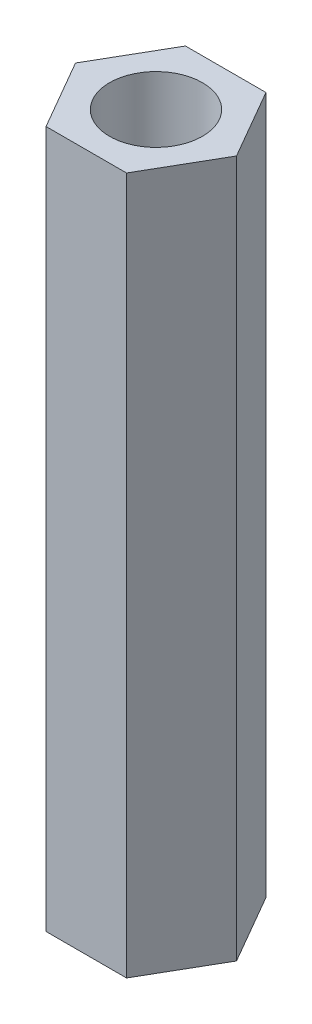
from build123d import *

# Parameters (mm, degrees)
EXTRUDE_1_DEPTH                 = 30
CUT_EXTRUDE_1_REACH             = 32
SKETCH_2_R                      = 2
CUT_EXTRUDE_1_DIRECTION_2_DEPTH = 1


with BuildPart() as part:
    # 草图1 → 凸台-拉伸1 (new body)
    with BuildSketch(Plane(origin=(0, 0, 0), x_dir=(1, 0, 0), z_dir=(0, 1, 0))):
        Polygon((-1.732050808, 3), (1.732050808, 3), (3.464101615, 0), (1.732050808, -3), (-1.732050808, -3), (-3.464101615, 0), align=None)
    extrude(amount=EXTRUDE_1_DEPTH)

    # 草图2 → 切除-拉伸1 (cut, up to next)
    with BuildSketch(Plane(origin=(0, 30, 0), x_dir=(1, 0, 0), z_dir=(0, 1, 0)), mode=Mode.PRIVATE) as cut_extrude_1_sk1:
        Circle(SKETCH_2_R)
    cut_extrude_1_tool1 = extrude(cut_extrude_1_sk1.sketch, amount=-CUT_EXTRUDE_1_REACH, mode=Mode.PRIVATE) & part.part
    add(cut_extrude_1_tool1.solids().sort_by_distance((0, 30, 0))[0], mode=Mode.SUBTRACT)

    # 草图2 → 切除-拉伸1 direction 2 (cut)
    with BuildSketch(Plane(origin=(0, 30, 0), x_dir=(1, 0, 0), z_dir=(0, 1, 0))):
        Circle(SKETCH_2_R)
    extrude(amount=CUT_EXTRUDE_1_DIRECTION_2_DEPTH, mode=Mode.SUBTRACT)


solid = part.part
